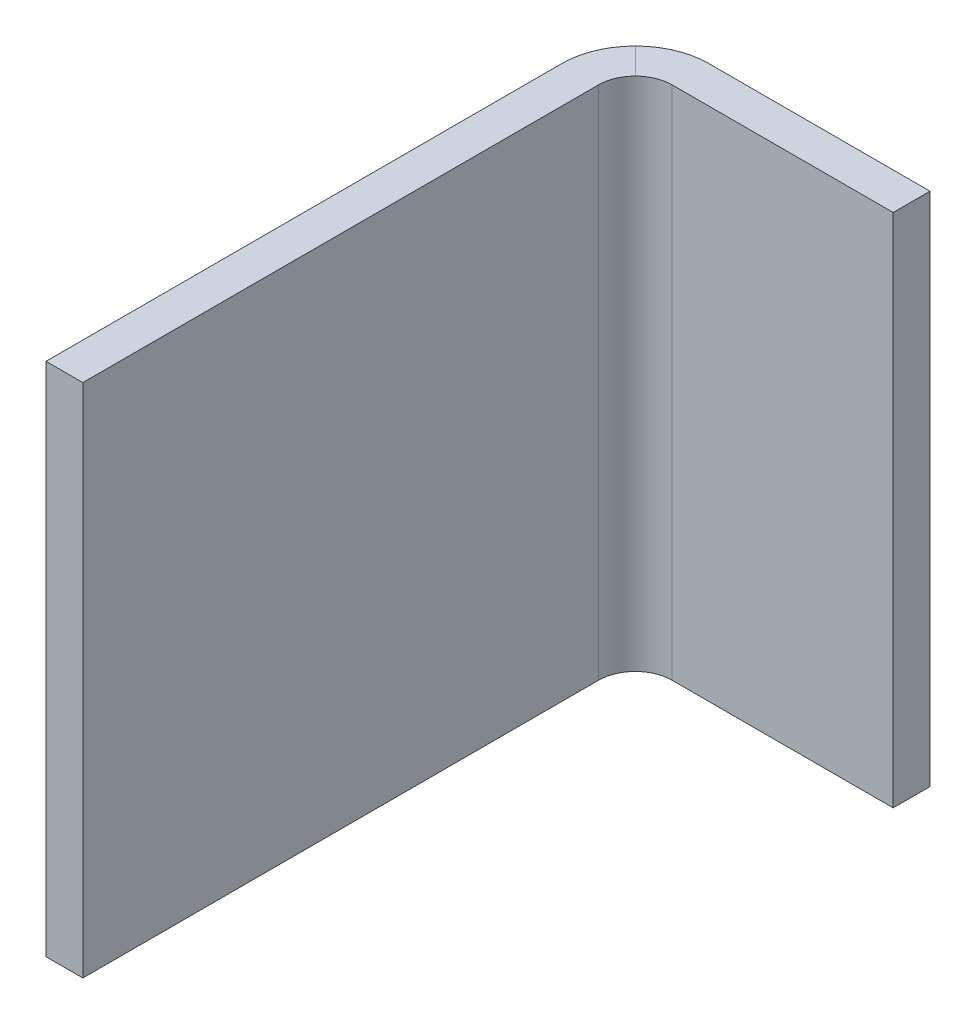
from build123d import *

# Parameters (mm, degrees)
SKETCH3_W = 3.175
SKETCH3_H = 44.45
FILLET1_R = 3.175
FILLET2_R = 6.35


with BuildPart() as part:
    # Sweep1: sweep along a path in Sketch4
    with BuildLine(Plane(origin=(0, 0, 0), x_dir=(1, 0, 0), z_dir=(0, 1, 0))) as sweep1_path:
        Line((0, 0), (0, 50.8))
        Line((0, 50.8), (25.4, 50.8))
    # Sketch3 → Sweep1 (sweep)
    with BuildSketch(Plane.XY):
        with Locations((1.5875, 0)):
            Rectangle(SKETCH3_W, SKETCH3_H)
    sweep(path=sweep1_path.line, transition=Transition.RIGHT)

    # Fillet1
    fillet1_edges = [part.edges().sort_by_distance(p)[0] for p in [
        (3.175, 0, -47.625),
    ]]
    fillet(fillet1_edges, radius=FILLET1_R)

    # Fillet2
    fillet2_edges = [part.edges().sort_by_distance(p)[0] for p in [
        (0, 0, -50.8),
    ]]
    fillet(fillet2_edges, radius=FILLET2_R)


solid = part.part
